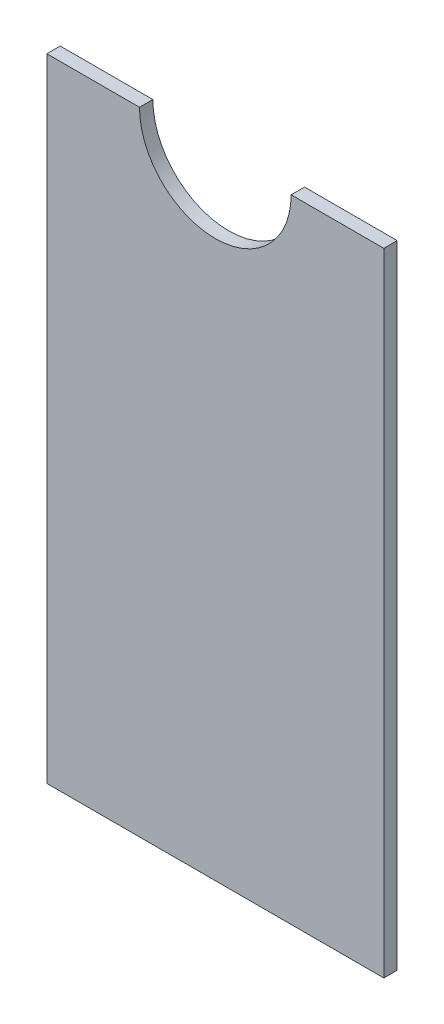
from build123d import *

# Parameters (mm, degrees)
BOSS_EXTRUDE1_DEPTH = 3.175


with BuildPart() as part:
    # Sketch1 → Boss-Extrude1 (new body)
    with BuildSketch(Plane.XY):
        with BuildLine():
            Line((18, 75), (40, 75))
            Line((40, 75), (40, -75))
            Line((40, -75), (-40, -75))
            Line((-40, -75), (-40, 75))
            Line((-40, 75), (-18, 75))
            ThreePointArc((-18, 75), (0, 57), (18, 75))
        make_face()
    extrude(amount=BOSS_EXTRUDE1_DEPTH)


solid = part.part
